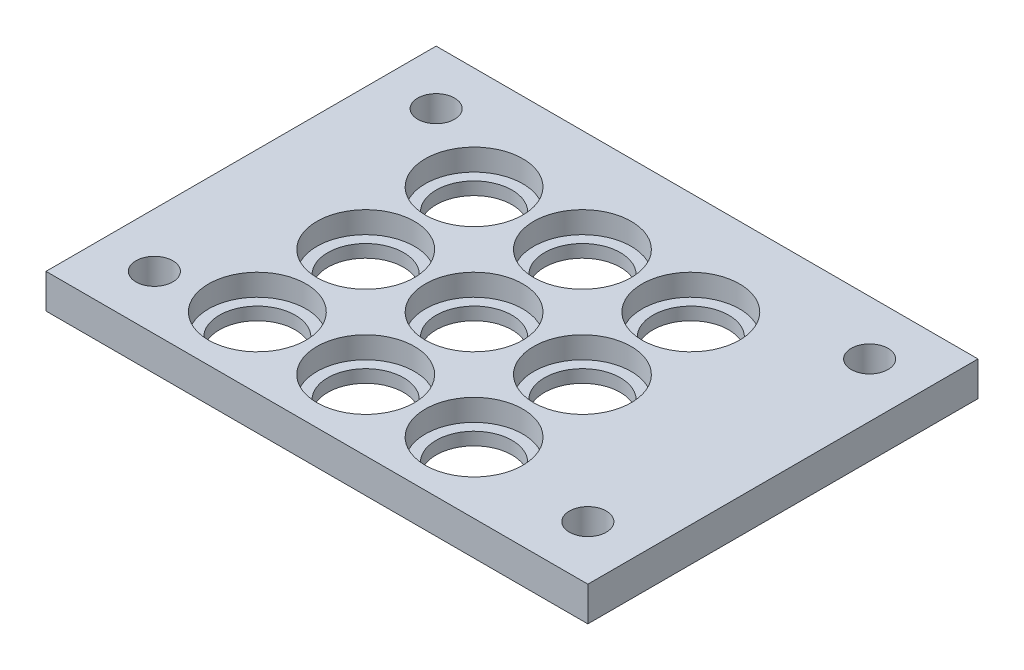
from build123d import *

# Parameters (mm, degrees)
SKETCH1_W           = 50
SKETCH1_H           = 36
SKETCH1_R           = 3.5
SKETCH1_R_2         = 1.7
BOSS_EXTRUDE1_DEPTH = 3.175
SKETCH2_R           = 4.5
CUT_EXTRUDE1_DEPTH  = 2


with BuildPart() as part:
    # Sketch1 → Boss-Extrude1 (new body)
    with BuildSketch(Plane(origin=(0, 0, 0), x_dir=(1, 0, 0), z_dir=(0, 1, 0))):
        with Locations((25, 18)):
            Rectangle(SKETCH1_W, SKETCH1_H)
        with Locations((13, 6.5)):
            Circle(SKETCH1_R, mode=Mode.SUBTRACT)
        with Locations((5, 5)):
            Circle(SKETCH1_R_2, mode=Mode.SUBTRACT)
        with Locations((5, 31)):
            Circle(SKETCH1_R_2, mode=Mode.SUBTRACT)
        with Locations((45, 31)):
            Circle(SKETCH1_R_2, mode=Mode.SUBTRACT)
        with Locations((45, 5)):
            Circle(SKETCH1_R_2, mode=Mode.SUBTRACT)
        with Locations((23, 6.5)):
            Circle(SKETCH1_R, mode=Mode.SUBTRACT)
        with Locations((33, 6.5)):
            Circle(SKETCH1_R, mode=Mode.SUBTRACT)
        with Locations((23, 16.5)):
            Circle(SKETCH1_R, mode=Mode.SUBTRACT)
        with Locations((33, 16.5)):
            Circle(SKETCH1_R, mode=Mode.SUBTRACT)
        with Locations((23, 26.5)):
            Circle(SKETCH1_R, mode=Mode.SUBTRACT)
        with Locations((33, 26.5)):
            Circle(SKETCH1_R, mode=Mode.SUBTRACT)
        with Locations((13, 16.5)):
            Circle(SKETCH1_R, mode=Mode.SUBTRACT)
        with Locations((13, 26.5)):
            Circle(SKETCH1_R, mode=Mode.SUBTRACT)
    extrude(amount=BOSS_EXTRUDE1_DEPTH)

    # Sketch2 → Cut-Extrude1 (cut)
    with BuildSketch(Plane(origin=(0, 3.175, 0), x_dir=(1, 0, 0), z_dir=(0, 1, 0))):
        with Locations((13, 26.5)):
            Circle(SKETCH2_R)
        with Locations((23, 26.5)):
            Circle(SKETCH2_R)
        with Locations((33, 26.5)):
            Circle(SKETCH2_R)
        with Locations((23, 16.5)):
            Circle(SKETCH2_R)
        with Locations((33, 16.5)):
            Circle(SKETCH2_R)
        with Locations((23, 6.5)):
            Circle(SKETCH2_R)
        with Locations((33, 6.5)):
            Circle(SKETCH2_R)
        with Locations((13, 16.5)):
            Circle(SKETCH2_R)
        with Locations((13, 6.5)):
            Circle(SKETCH2_R)
    extrude(amount=-CUT_EXTRUDE1_DEPTH, mode=Mode.SUBTRACT)


solid = part.part
